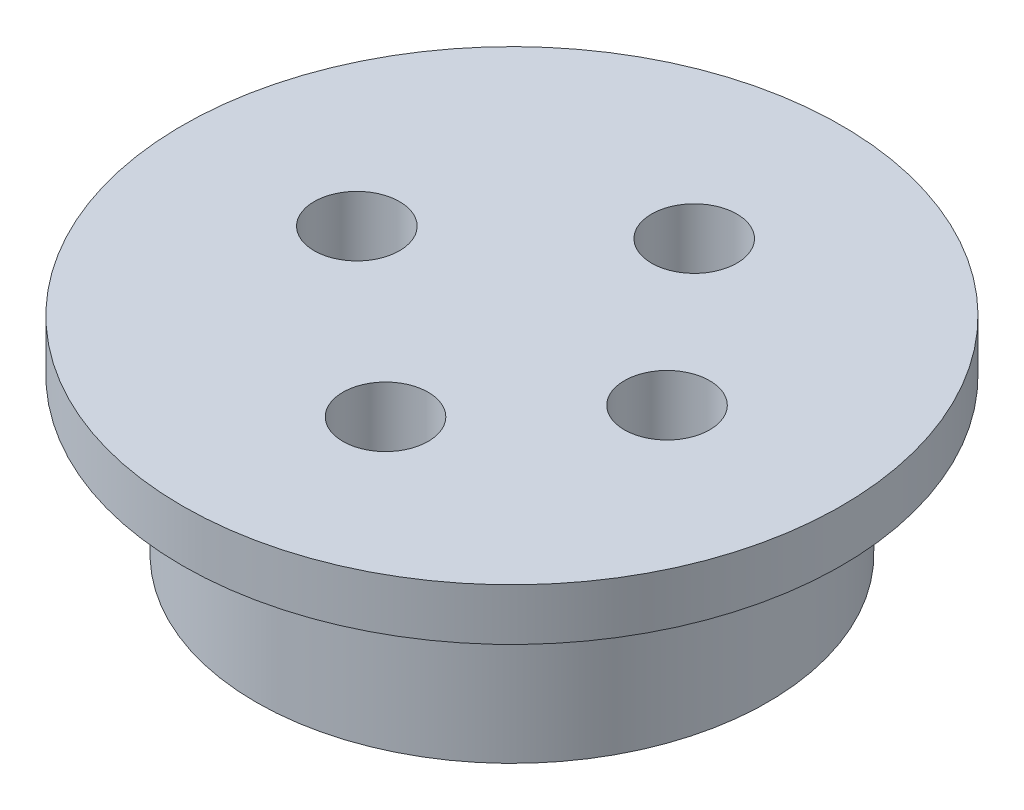
from build123d import *

# Parameters (mm, degrees)
SKETCH2_R           = 9.9
BOSS_EXTRUDE1_DEPTH = 8
SKETCH2_3_R         = 12.75
BOSS_EXTRUDE2_DEPTH = 2
SKETCH2_4_R         = 1.65
CUT_EXTRUDE1_DEPTH  = 9
CUT_EXTRUDE2_START  = -8
SKETCH2_5_R         = 3
CUT_EXTRUDE2_DEPTH  = 3.1


with BuildPart() as part:
    # Sketch2 → Boss-Extrude1 (new body)
    with BuildSketch(Plane(origin=(0, 0, 0), x_dir=(1, 0, 0), z_dir=(0, 1, 0))):
        with Locations((-0.930712346, 0.804578045)):
            Circle(SKETCH2_R)
    extrude(amount=-BOSS_EXTRUDE1_DEPTH)

    # Sketch2_3 → Boss-Extrude2 (add)
    with BuildSketch(Plane(origin=(0, 0, 0), x_dir=(1, 0, 0), z_dir=(0, 1, 0))):
        with Locations((-0.930712346, 0.804578045)):
            Circle(SKETCH2_3_R)
    extrude(amount=-BOSS_EXTRUDE2_DEPTH)

    # Sketch2_4 → Cut-Extrude1 (cut, through all)
    with BuildSketch(Plane(origin=(0, 0, 0), x_dir=(1, 0, 0), z_dir=(0, 1, 0))):
        with Locations((0.012181629, 6.914065552)):
            Circle(SKETCH2_4_R)
        with Locations((0.012181629, -5.027976136)):
            Circle(SKETCH2_4_R)
        with Locations((-6.930712346, 0.804578045)):
            Circle(SKETCH2_4_R)
        with Locations((5.069287654, 0.804578045)):
            Circle(SKETCH2_4_R)
    extrude(amount=-CUT_EXTRUDE1_DEPTH, mode=Mode.SUBTRACT)

    # Sketch2_5 → Cut-Extrude2 (cut)
    with BuildSketch(Plane(origin=(0, 0, 0), x_dir=(1, 0, 0), z_dir=(0, 1, 0)).offset(CUT_EXTRUDE2_START)):
        with Locations((0.012181629, 6.914065552)):
            Circle(SKETCH2_5_R)
        with Locations((0.012181629, -5.027976136)):
            Circle(SKETCH2_5_R)
    extrude(amount=CUT_EXTRUDE2_DEPTH, mode=Mode.SUBTRACT)


solid = part.part
